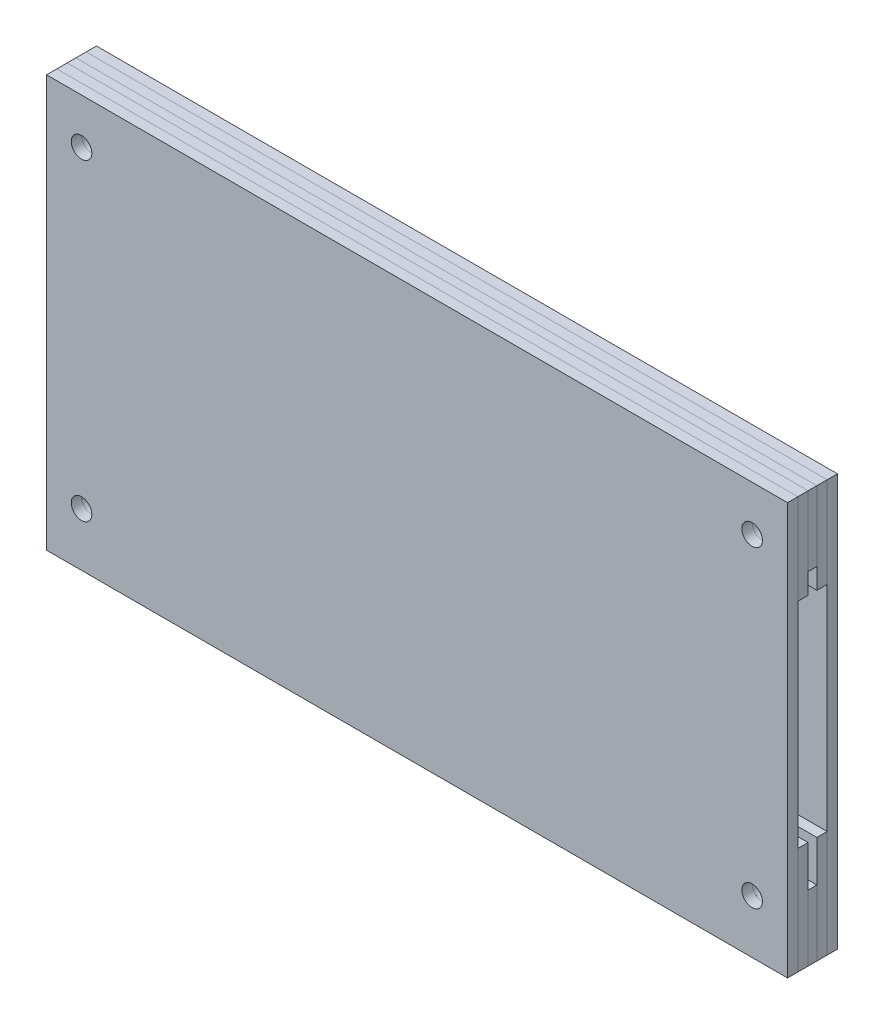
from build123d import *

# Parameters (mm, degrees)
SKETCH1_W               = 228.6
SKETCH1_H               = 127
BOSS_EXTRUDE1_DEPTH     = 3.175
BOSS_EXTRUDE2_DEPTH     = 3.175
BOSS_EXTRUDE4_DEPTH     = 2.7051
SKETCH6_R               = 3.175
CUT_EXTRUDE1_DEPTH      = 4.175
CUT_EXTRUDE1_DEPTH_BACK = 13.2301


with BuildPart() as part:
    # Sketch1 → Boss-Extrude1 (new body)
    with BuildSketch(Plane.XY):
        Rectangle(SKETCH1_W, SKETCH1_H)
    extrude(amount=BOSS_EXTRUDE1_DEPTH)


with BuildPart() as body_2:
    # Sketch2 → Boss-Extrude2 (new body)
    with BuildSketch(Plane(origin=(0, 0, 0), x_dir=(-1, 0, 0), z_dir=(0, 0, -1))):
        Polygon((-114.3, 63.5), (-114.3, 35.56), (92.71, 35.56), (92.71, -30.48), (-114.3, -30.48), (-114.3, -63.5), (92.173439785, -63.5), (114.3, -63.5), (114.3, 63.5), align=None)
    extrude(amount=BOSS_EXTRUDE2_DEPTH)


with BuildPart() as body_3:
    # Sketch4 → Boss-Extrude4 (new body)
    with BuildSketch(Plane(origin=(0, 0, -3.175), x_dir=(-1, 0, 0), z_dir=(0, 0, -1))):
        Polygon((-114.3, 41.91), (101.6, 41.91), (101.6, -43.18), (-114.3, -43.18), (-114.3, -63.5), (114.3, -63.5), (114.3, 63.5), (-114.3, 63.5), align=None)
    extrude(amount=BOSS_EXTRUDE4_DEPTH)


with BuildPart() as body_4:
    # Mirror1: mirrored copy
    add(part.part.mirror(Plane(origin=(0, 0, -4.52755), x_dir=(1, 0, 0), z_dir=(0, 0, -1))))


with BuildPart() as body_5:
    # Mirror1 2: mirrored copy
    add(body_2.part.mirror(Plane(origin=(0, 0, -4.52755), x_dir=(1, 0, 0), z_dir=(0, 0, -1))))


with BuildPart() as cut_extrude1_tool:
    # Sketch6 → Cut-Extrude1 (new body, two sides)
    with BuildSketch(Plane.XY) as cut_extrude1_sk:
        with Locations((-103.505, 49.53)):
            Circle(SKETCH6_R)
        with Locations((-103.505, -46.99)):
            Circle(SKETCH6_R)
        with Locations((103.378, 49.53)):
            Circle(SKETCH6_R)
        with Locations((103.378, -46.99)):
            Circle(SKETCH6_R)
    extrude(amount=CUT_EXTRUDE1_DEPTH)
    extrude(cut_extrude1_sk.sketch, amount=-CUT_EXTRUDE1_DEPTH_BACK)


with BuildPart() as part_1:
    add(part.part)

    # Cut-Extrude1: cut by cut_extrude1_tool
    add(cut_extrude1_tool.part, mode=Mode.SUBTRACT)


with BuildPart() as body_2_1:
    add(body_2.part)

    # Cut-Extrude1: cut by cut_extrude1_tool
    add(cut_extrude1_tool.part, mode=Mode.SUBTRACT)


with BuildPart() as body_3_1:
    add(body_3.part)

    # Cut-Extrude1: cut by cut_extrude1_tool
    add(cut_extrude1_tool.part, mode=Mode.SUBTRACT)


with BuildPart() as body_4_1:
    add(body_4.part)

    # Cut-Extrude1: cut by cut_extrude1_tool
    add(cut_extrude1_tool.part, mode=Mode.SUBTRACT)


with BuildPart() as body_5_1:
    add(body_5.part)

    # Cut-Extrude1: cut by cut_extrude1_tool
    add(cut_extrude1_tool.part, mode=Mode.SUBTRACT)


solid = Compound([part_1.part, body_2_1.part, body_3_1.part, body_4_1.part, body_5_1.part])
